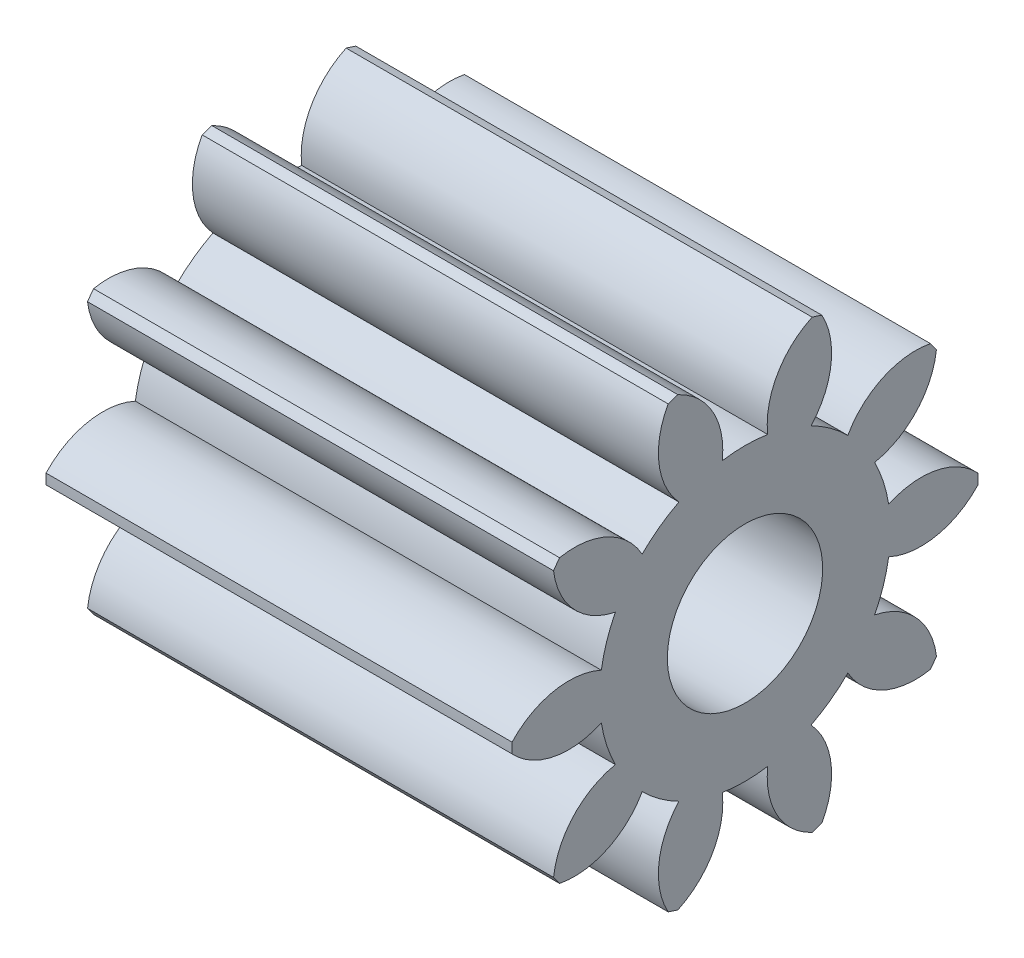
from build123d import *

# Parameters (mm, degrees)
BASPROSKE_W     = 3
BASPROSKE_H     = 1.5
TOOTHCUT_DEPTH  = 4.674234614
TEETHCUTS_COUNT = 10
TEETHCUTS_ANGLE = 324
BORSKE_R        = 0.5
BORE_DEPTH      = 50.0000508


with BuildPart() as part:
    # BasProSke → Base-Revolve (revolve)
    with BuildSketch(Plane(origin=(0, 0, 0), x_dir=(1, 0, 0), z_dir=(0, 1, 0)), mode=Mode.PRIVATE) as base_revolve_sk:
        with Locations((1.5, 0.75)):
            Rectangle(BASPROSKE_W, BASPROSKE_H)
    revolve(base_revolve_sk.sketch.rotate(Axis((-10, 0, 0), (1, 0, 0)), 180), axis=Axis((-10, 0, 0), (1, 0, 0)))

    # TooCutSke → ToothCut (cut, through all)
    with BuildSketch(Plane(origin=(0, 0, 0), x_dir=(0, 0, -1), z_dir=(1, 0, 0))):
        with BuildLine():
            ThreePointArc((0.146321185, 0.924998573), (0, 0.9365), (-0.146321185, 0.924998573))
            ThreePointArc((-0.146321185, 0.924998573), (-0.216454601, 1.244005636), (-0.468585949, 1.451644712))
            ThreePointArc((-0.468585949, 1.451644712), (0, 1.5254), (0.468585949, 1.451644712))
            ThreePointArc((0.468585949, 1.451644712), (0.216454601, 1.244005636), (0.146321185, 0.924998573))
        make_face()
    toothcut = extrude(amount=TOOTHCUT_DEPTH, mode=Mode.SUBTRACT)

    # TeethCuts: ToothCut ×10 about axis
    teethcuts_axis = Axis((-10, 0, 0), (1, 0, 0))
    for i in range(1, TEETHCUTS_COUNT):
        add(toothcut.rotate(teethcuts_axis, i * TEETHCUTS_ANGLE / (TEETHCUTS_COUNT - 1)), mode=Mode.SUBTRACT)

    # BorSke → Bore (cut, symmetric)
    with BuildSketch(Plane(origin=(0, 0, 0), x_dir=(0, 0, -1), z_dir=(1, 0, 0))):
        with Locations(Location((0, 0, 0), (0, 0, 180))):
            Circle(BORSKE_R)
    extrude(amount=BORE_DEPTH, both=True, mode=Mode.SUBTRACT)


solid = part.part
